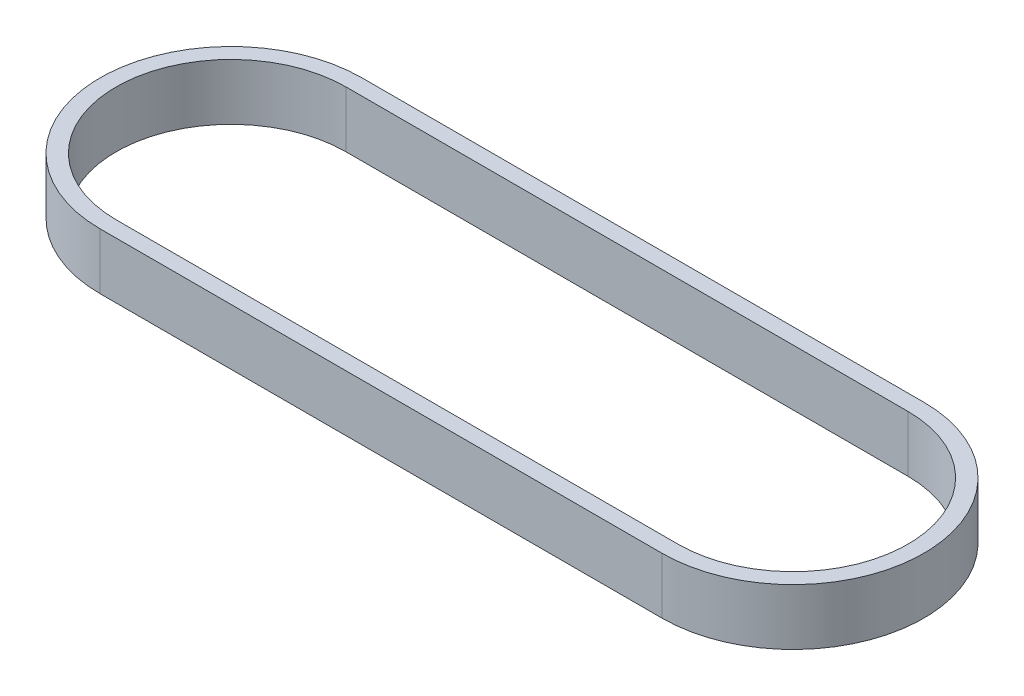
from build123d import *

# Parameters (mm, degrees)
BOSS_EXTRUDE1_DEPTH = 9


with BuildPart() as part:
    # Sketch1 → Boss-Extrude1 (new body)
    with BuildSketch(Plane(origin=(0, 0, 0), x_dir=(1, 0, 0), z_dir=(0, 1, 0))):
        with BuildLine():
            Line((44.99991, -20.955), (-44.99991, -20.955))
            ThreePointArc((-44.99991, -20.955), (-65.95491, 0), (-44.99991, 20.955))
            Line((-44.99991, 20.955), (44.99991, 20.955))
            ThreePointArc((44.99991, 20.955), (65.95491, 0), (44.99991, -20.955))
        make_face()
        with BuildLine():
            Line((44.99991, -18.415), (-44.99991, -18.415))
            ThreePointArc((-44.99991, -18.415), (-63.41491, 0), (-44.99991, 18.415))
            Line((-44.99991, 18.415), (44.99991, 18.415))
            ThreePointArc((44.99991, 18.415), (63.41491, 0), (44.99991, -18.415))
        make_face(mode=Mode.SUBTRACT)
    extrude(amount=BOSS_EXTRUDE1_DEPTH)


solid = part.part
